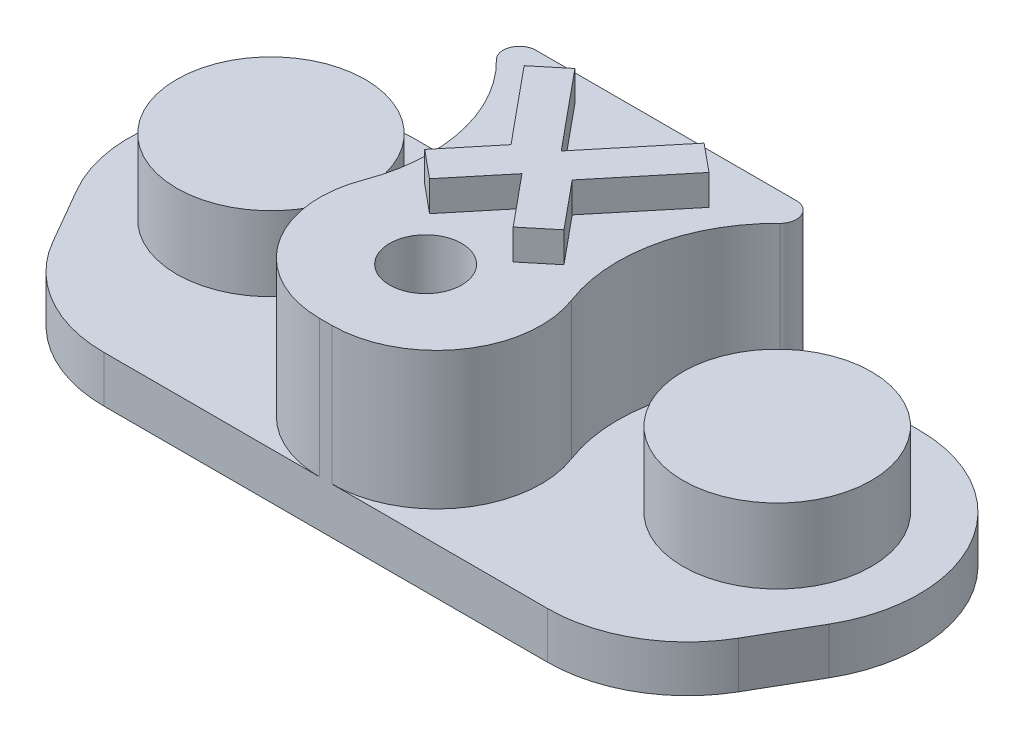
from build123d import *

# Parameters (mm, degrees)
BOSS_EXTRUDE1_START        = 0.2
SKETCH2_R                  = 4.05
BOSS_EXTRUDE1_DEPTH        = 0.2
BOSS_EXTRUDE1_DEPTH_BACK   = 3
BOSS_EXTRUDE1_2_DEPTH      = 0.2
BOSS_EXTRUDE1_2_DEPTH_BACK = 3
BOSS_EXTRUDE2_START        = 0.4
SKETCH2_8_R                = 2.95
BOSS_EXTRUDE2_DEPTH        = 2
BOSS_EXTRUDE3_START        = 0.4
SKETCH2_10_R               = 2.95
BOSS_EXTRUDE3_DEPTH        = 5.9
BOSS_EXTRUDE4_START        = -5.5
SKETCH2_11_R               = 2.95
SKETCH2_11_R_2             = 1.55
BOSS_EXTRUDE4_DEPTH        = 4.3
BOSS_EXTRUDE5_DEPTH        = 1.3


with BuildPart() as part:
    # Sketch2 → Boss-Extrude1 (new body, two sides)
    with BuildSketch(Plane.XZ.offset(17.641705272).offset(BOSS_EXTRUDE1_START)) as boss_extrude1_sk:
        with Locations((41.993031242, -65.814080244)):
            Circle(SKETCH2_R)
    extrude(amount=BOSS_EXTRUDE1_DEPTH)
    extrude(boss_extrude1_sk.sketch, amount=-BOSS_EXTRUDE1_DEPTH_BACK)



with BuildPart() as body_2:
    # Sketch2 → Boss-Extrude1 2 (new body, two sides)
    with BuildSketch(Plane.XZ.offset(17.641705272).offset(BOSS_EXTRUDE1_START)) as boss_extrude1_2_sk:
        with Locations((63.743031242, -65.814080244)):
            Circle(SKETCH2_R)
    extrude(amount=BOSS_EXTRUDE1_2_DEPTH)
    extrude(boss_extrude1_2_sk.sketch, amount=-BOSS_EXTRUDE1_2_DEPTH_BACK)


with BuildPart() as part_1:
    add(part.part)

    add(body_2.part)  # Boss-Extrude2 merges body 2
    # Sketch2_8 → Boss-Extrude2 (add)
    with BuildSketch(Plane.XZ.offset(17.641705272).offset(BOSS_EXTRUDE2_START)):
        with BuildLine():
            Line((43.332476509, -57.294092988), (62.403585975, -57.294092988))
            ThreePointArc((62.403585975, -57.294092988), (65.403585975, -58.097940565), (67.599738397, -60.294092988))
            Line((67.599738397, -60.294092988), (69.025786205, -62.764080244))
            ThreePointArc((69.025786205, -62.764080244), (69.025786205, -68.864080244), (63.743031242, -71.914080244))
            Line((63.743031242, -71.914080244), (41.993031242, -71.914080244))
            ThreePointArc((41.993031242, -71.914080244), (36.710276279, -68.864080244), (36.710276279, -62.764080244))
            Line((36.710276279, -62.764080244), (38.136324086, -60.294092988))
            ThreePointArc((38.136324086, -60.294092988), (40.332476509, -58.097940565), (43.332476509, -57.294092988))
        make_face()
        with Locations((52.868031242, -61.584989522)):
            Circle(SKETCH2_8_R, mode=Mode.SUBTRACT)
    extrude(amount=BOSS_EXTRUDE2_DEPTH)

    # Sketch2_10 → Boss-Extrude3 (add)
    with BuildSketch(Plane.XZ.offset(17.641705272).offset(BOSS_EXTRUDE3_START)):
        with BuildLine():
            Line((53.128785981, -57.294092988), (52.607276503, -57.294092988))
            ThreePointArc((52.607276503, -57.294092988), (48.904424631, -59.236968036), (48.39898543, -63.387920534))
            ThreePointArc((48.39898543, -63.387920534), (48.681708279, -67.291950162), (46.7804094, -70.713417992))
            ThreePointArc((46.7804094, -70.713417992), (46.621377652, -71.478216974), (47.269630525, -71.914080244))
            Line((47.269630525, -71.914080244), (58.466431958, -71.914080244))
            ThreePointArc((58.466431958, -71.914080244), (59.114684832, -71.478216974), (58.955653084, -70.713417992))
            ThreePointArc((58.955653084, -70.713417992), (57.054354205, -67.291950162), (57.337077053, -63.387920534))
            ThreePointArc((57.337077053, -63.387920534), (56.831637852, -59.236968036), (53.128785981, -57.294092988))
        make_face()
        with Locations((52.868031242, -61.584989522)):
            Circle(SKETCH2_10_R, mode=Mode.SUBTRACT)
    extrude(amount=-BOSS_EXTRUDE3_DEPTH)

    # Sketch2_11 → Boss-Extrude4 (add)
    with BuildSketch(Plane.XZ.offset(17.641705272).offset(BOSS_EXTRUDE4_START)):
        with Locations((52.868031242, -61.584989522)):
            Circle(SKETCH2_11_R)
        with Locations((52.868031242, -61.584989522)):
            Circle(SKETCH2_11_R_2, mode=Mode.SUBTRACT)
    extrude(amount=BOSS_EXTRUDE4_DEPTH)

    # Sketch3 → Boss-Extrude5 (add)
    with BuildSketch(Plane(origin=(0, -12.141705272, 0), x_dir=(1, 0, 0), z_dir=(0, 1, 0))):
        Polygon((50.091896525, 70.773300161), (52.868031242, 67.410555891), (55.644165958, 70.773300161), (56.83946806, 69.786510981), (54.182101398, 66.567630982), (55.859200009, 64.536154012), (54.663897908, 63.549364832), (52.868031242, 65.724706073), (51.072164576, 63.549364832), (49.876862474, 64.536154012), (51.553961085, 66.567630982), (48.896594423, 69.786510981), align=None)
    extrude(amount=BOSS_EXTRUDE5_DEPTH)


solid = part_1.part
